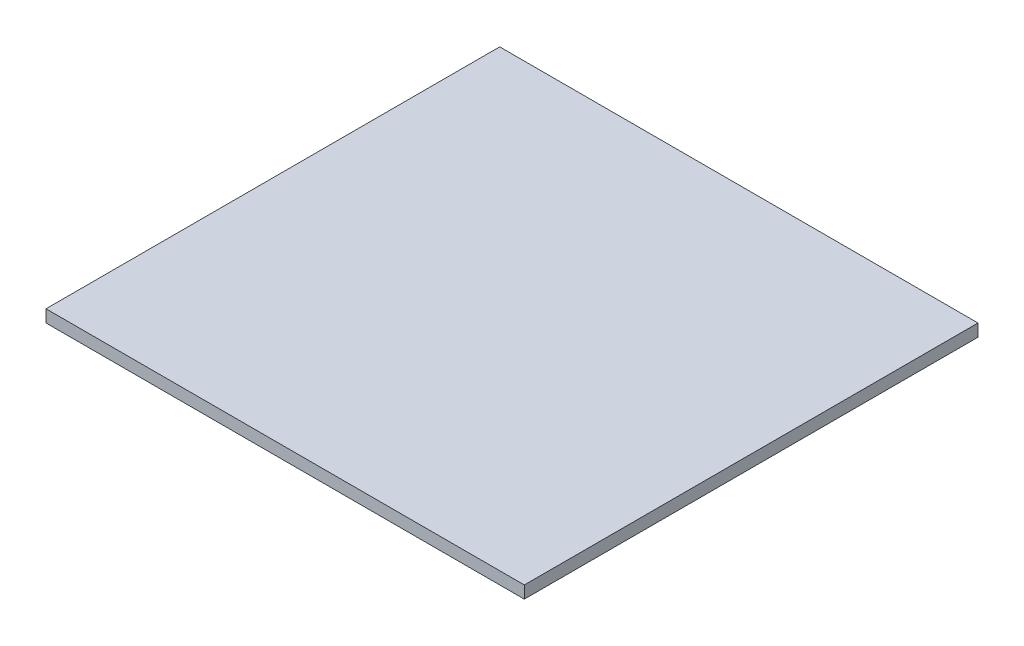
from build123d import *

# Parameters (mm, degrees)
CROQUIS1_W              = 73.8
CROQUIS1_H              = 70
SALIENTE_EXTRUIR1_DEPTH = 1.9


with BuildPart() as part:
    # Croquis1 → Saliente-Extruir1 (new body)
    with BuildSketch(Plane(origin=(0, 0, 0), x_dir=(1, 0, 0), z_dir=(0, 1, 0))):
        Rectangle(CROQUIS1_W, CROQUIS1_H)
    extrude(amount=SALIENTE_EXTRUIR1_DEPTH)


solid = part.part
